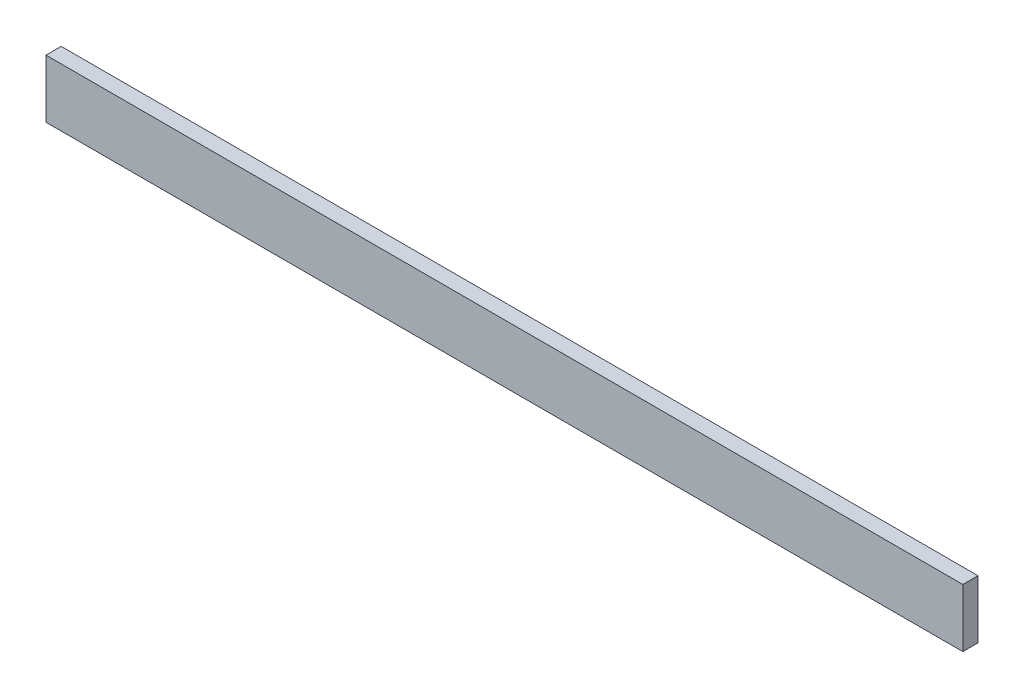
from build123d import *

# Parameters (mm, degrees)
SKETCH1_W           = 603.641687447
SKETCH1_H           = 38.292622135
BOSS_EXTRUDE1_DEPTH = 10


with BuildPart() as part:
    # Sketch1 → Boss-Extrude1 (new body)
    with BuildSketch(Plane.XY):
        with Locations((301.820843723, 19.146311068)):
            Rectangle(SKETCH1_W, SKETCH1_H)
    extrude(amount=BOSS_EXTRUDE1_DEPTH)


solid = part.part
